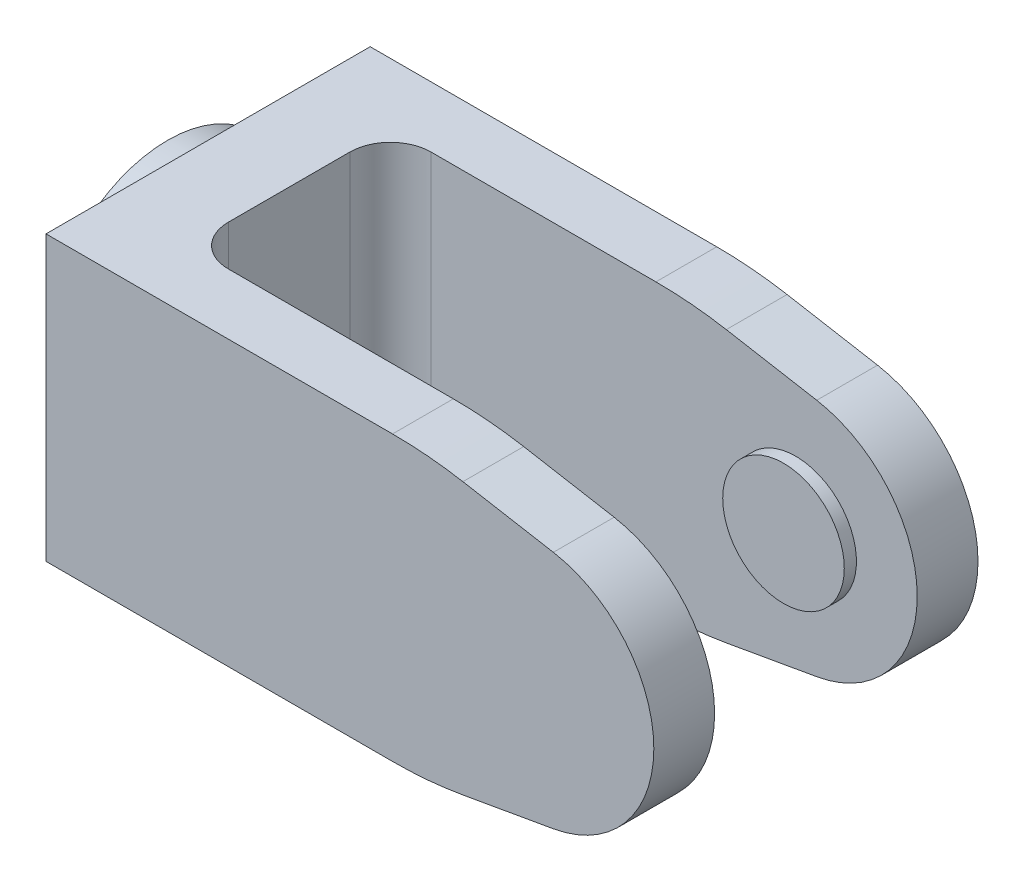
from build123d import *

# Parameters (mm, degrees)
BOSS_EXTRUDE1_DEPTH = 40
SKETCH2_W           = 154.782746008
SKETCH2_H           = 50
CUT_EXTRUDE1_DEPTH  = 113.744158528
SKETCH2_2_W         = 154.782746008
SKETCH2_2_H         = 50
CUT_EXTRUDE2_DEPTH  = 113.744158528
SKETCH3_R           = 15
BOSS_EXTRUDE2_DEPTH = 3
SKETCH4_R           = 30
BOSS_EXTRUDE3_DEPTH = 10
SKETCH5_R           = 25
BOSS_EXTRUDE4_DEPTH = 3
FILLET1_R           = 100
FILLET2_R           = 100
FILLET3_R           = 10


with BuildPart() as part:
    # Sketch1 → Boss-Extrude1 (new, symmetric)
    with BuildSketch(Plane.XY):
        with BuildLine():
            Line((-54.159677949, -43.884825983), (40.108572858, -43.884825983))
            Line((40.108572858, -43.884825983), (71.049767381, -38.429058573))
            ThreePointArc((71.049767381, -38.429058573), (95.840322051, -8.884825983), (71.049767381, 20.659406608))
            Line((71.049767381, 20.659406608), (40.108572858, 26.115174017))
            Line((40.108572858, 26.115174017), (-54.159677949, 26.115174017))
            Line((-54.159677949, 26.115174017), (-54.159677949, -43.884825983))
        make_face()
    extrude(amount=BOSS_EXTRUDE1_DEPTH, both=True)

    # Sketch2 → Cut-Extrude1 (cut, through all)
    with BuildSketch(Plane(origin=(0, 0, 0), x_dir=(1, 0, 0), z_dir=(0, 1, 0))):
        with Locations((43.231695055, 0)):
            Rectangle(SKETCH2_W, SKETCH2_H)
    extrude(amount=-CUT_EXTRUDE1_DEPTH, mode=Mode.SUBTRACT)

    # Sketch2_2 → Cut-Extrude2 (cut, through all)
    with BuildSketch(Plane(origin=(0, 0, 0), x_dir=(1, 0, 0), z_dir=(0, 1, 0))):
        with Locations((43.231695055, 0)):
            Rectangle(SKETCH2_2_W, SKETCH2_2_H)
    extrude(amount=CUT_EXTRUDE2_DEPTH, mode=Mode.SUBTRACT)

    # Sketch3 → Boss-Extrude2 (add)
    with BuildSketch(Plane.XY.offset(-25)):
        with Locations((65.840322051, -8.884825983)):
            Circle(SKETCH3_R)
    boss_extrude2 = extrude(amount=BOSS_EXTRUDE2_DEPTH)

    # Mirror1: Boss-Extrude2 across plane
    add(boss_extrude2.mirror(Plane.XY))

    # Sketch4 → Boss-Extrude3 (add)
    with BuildSketch(Plane.ZY.offset(54.159677949)):
        with Locations((0, -8.884825983)):
            Circle(SKETCH4_R)
    extrude(amount=BOSS_EXTRUDE3_DEPTH)

    # Sketch5 → Boss-Extrude4 (add)
    with BuildSketch(Plane.ZY.offset(64.159677949)):
        with Locations((0, -8.884825983)):
            Circle(SKETCH5_R)
    extrude(amount=BOSS_EXTRUDE4_DEPTH)

    # Fillet1
    fillet1_edges = [part.edges().sort_by_distance(p)[0] for p in [
        (40.108572858, 26.115174017, 32.5),
        (40.108572858, 26.115174017, -32.5),
    ]]
    fillet(fillet1_edges, radius=FILLET1_R)

    # Fillet2
    fillet2_edges = [part.edges().sort_by_distance(p)[0] for p in [
        (40.108572858, -43.884825983, -32.5),
        (40.108572858, -43.884825983, 32.5),
    ]]
    fillet(fillet2_edges, radius=FILLET2_R)

    # Fillet3
    fillet3_edges = [part.edges().sort_by_distance(p)[0] for p in [
        (-34.159677949, -8.884825983, 25),
        (-34.159677949, -8.884825983, -25),
    ]]
    fillet(fillet3_edges, radius=FILLET3_R)


solid = part.part
